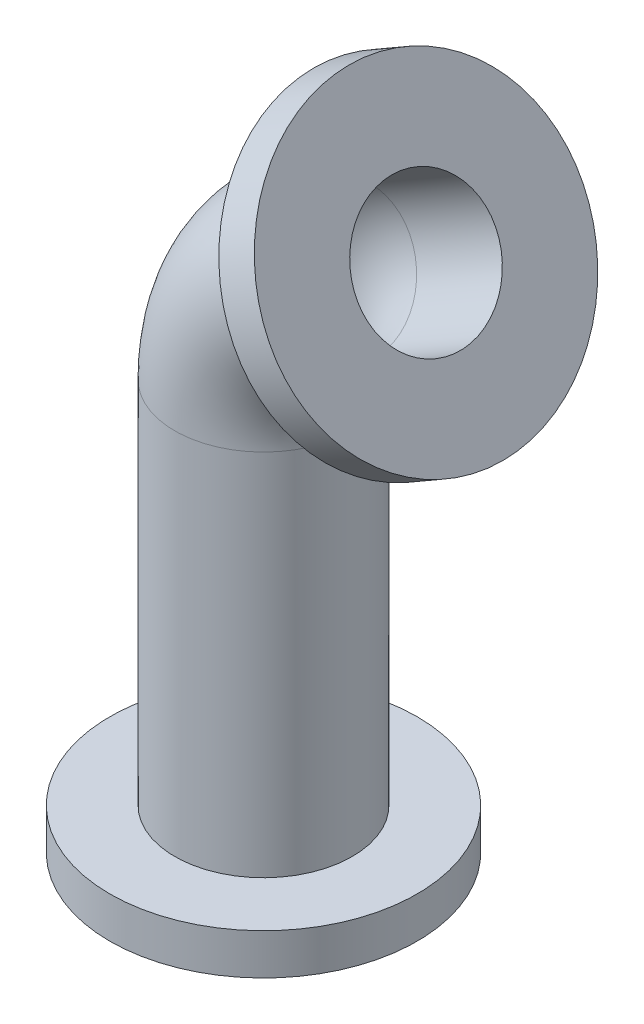
from build123d import *

# Parameters (mm, degrees)
SKIZZE2_R                       = 26
SKIZZE2_R_2                     = 20
SKIZZE3_R                       = 45
SKIZZE3_R_2                     = 26
AUFSATZ_LINEAR_AUSTRAGEN1_DEPTH = 12
SKIZZE4_R                       = 45
SKIZZE4_R_2                     = 20
AUFSATZ_LINEAR_AUSTRAGEN2_DEPTH = 12


with BuildPart() as part:
    # Austragung-Dünn1: sweep along a path in Skizze1
    with BuildLine(Plane.XY) as austragung_d_nn1_path:
        Line((0, 0), (0, 120))
        ThreePointArc((0, 120), (6.02885683, 142.5), (22.5, 158.97114317))
        Line((22.5, 158.97114317), (47.61473671, 173.47114317))
    # Skizze2 → Austragung-Dünn1 (sweep)
    with BuildSketch(Plane(origin=(0, 0, 0), x_dir=(1, 0, 0), z_dir=(0, 1, 0))):
        Circle(SKIZZE2_R)
        Circle(SKIZZE2_R_2, mode=Mode.SUBTRACT)
    sweep(path=austragung_d_nn1_path.line)

    # Skizze3 → Aufsatz-Linear austragen1 (add)
    with BuildSketch(Plane.XZ):
        with Locations(Location((0, 0, 0), (0, 0, 270))):  # turned: the seam where the file's is
            Circle(SKIZZE3_R)
        with Locations(Location((0, 0, 0), (0, 0, 270))):  # turned: the seam where the file's is
            Circle(SKIZZE3_R_2, mode=Mode.SUBTRACT)
    extrude(amount=-AUFSATZ_LINEAR_AUSTRAGEN1_DEPTH)

    # Skizze4 → Aufsatz-Linear austragen2 (add)
    with BuildSketch(Plane(origin=(110.826260937, 63.985571585, 0), x_dir=(0, 0, -1), z_dir=(0.866025404, 0.5, 0))):
        with Locations(Location((0, 126.423048454, 0), (0, 0, 90))):  # turned: the seam where the file's is
            Circle(SKIZZE4_R)
        with Locations(Location((0, 126.423048454, 0), (0, 0, 90))):  # turned: the seam where the file's is
            Circle(SKIZZE4_R_2, mode=Mode.SUBTRACT)
    extrude(amount=-AUFSATZ_LINEAR_AUSTRAGEN2_DEPTH)


solid = part.part
